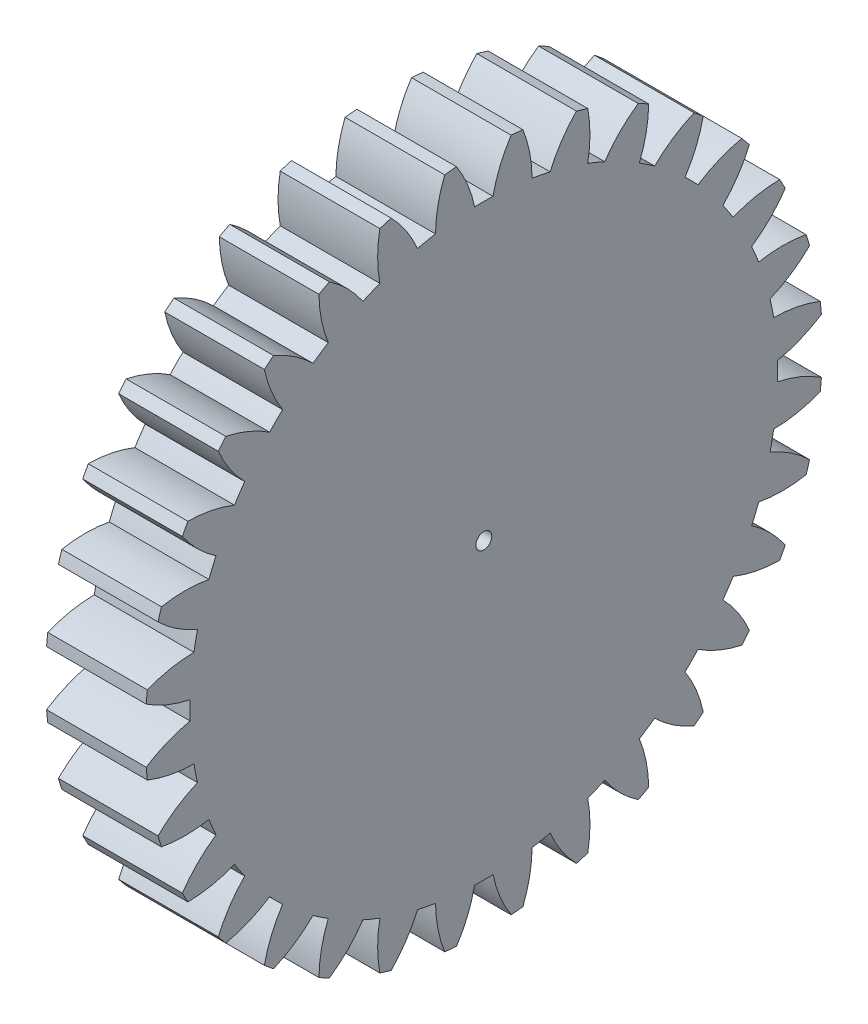
from build123d import *

# Parameters (mm, degrees)
BASPROSKE_W     = 5
BASPROSKE_H     = 17
TOOTHCUT_DEPTH  = 25.556058316
TEETHCUTS_COUNT = 32
TEETHCUTS_ANGLE = 348.75
BORSKE_R        = 0.4
BORE_DEPTH      = 50.0000508


with BuildPart() as part:
    # BasProSke → Base-Revolve (revolve)
    with BuildSketch(Plane(origin=(0, 0, 0), x_dir=(1, 0, 0), z_dir=(0, 1, 0)), mode=Mode.PRIVATE) as base_revolve_sk:
        with Locations((2.5, 8.5)):
            Rectangle(BASPROSKE_W, BASPROSKE_H)
    revolve(base_revolve_sk.sketch.rotate(Axis((-10, 0, 0), (1, 0, 0)), 180), axis=Axis((-10, 0, 0), (1, 0, 0)))

    # TooCutSke → ToothCut (cut, through all)
    with BuildSketch(Plane(origin=(0, 0, 0), x_dir=(0, 0, -1), z_dir=(1, 0, 0))):
        with BuildLine():
            ThreePointArc((0.462036907, 14.741761187), (0, 14.749), (-0.462036907, 14.741761187))
            ThreePointArc((-0.462036907, 14.741761187), (-0.81854142, 15.899240468), (-1.386721275, 16.9688317))
            ThreePointArc((-1.386721275, 16.9688317), (0, 17.0254), (1.386721275, 16.9688317))
            ThreePointArc((1.386721275, 16.9688317), (0.81854142, 15.899240468), (0.462036907, 14.741761187))
        make_face()
    toothcut = extrude(amount=TOOTHCUT_DEPTH, mode=Mode.SUBTRACT)

    # TeethCuts: ToothCut ×32 about axis
    teethcuts_axis = Axis((-10, 0, 0), (1, 0, 0))
    for i in range(1, TEETHCUTS_COUNT):
        add(toothcut.rotate(teethcuts_axis, i * TEETHCUTS_ANGLE / (TEETHCUTS_COUNT - 1)), mode=Mode.SUBTRACT)

    # BorSke → Bore (cut, symmetric)
    with BuildSketch(Plane(origin=(0, 0, 0), x_dir=(0, 0, -1), z_dir=(1, 0, 0))):
        with Locations(Location((0, 0, 0), (0, 0, 180))):
            Circle(BORSKE_R)
    extrude(amount=BORE_DEPTH, both=True, mode=Mode.SUBTRACT)


solid = part.part
